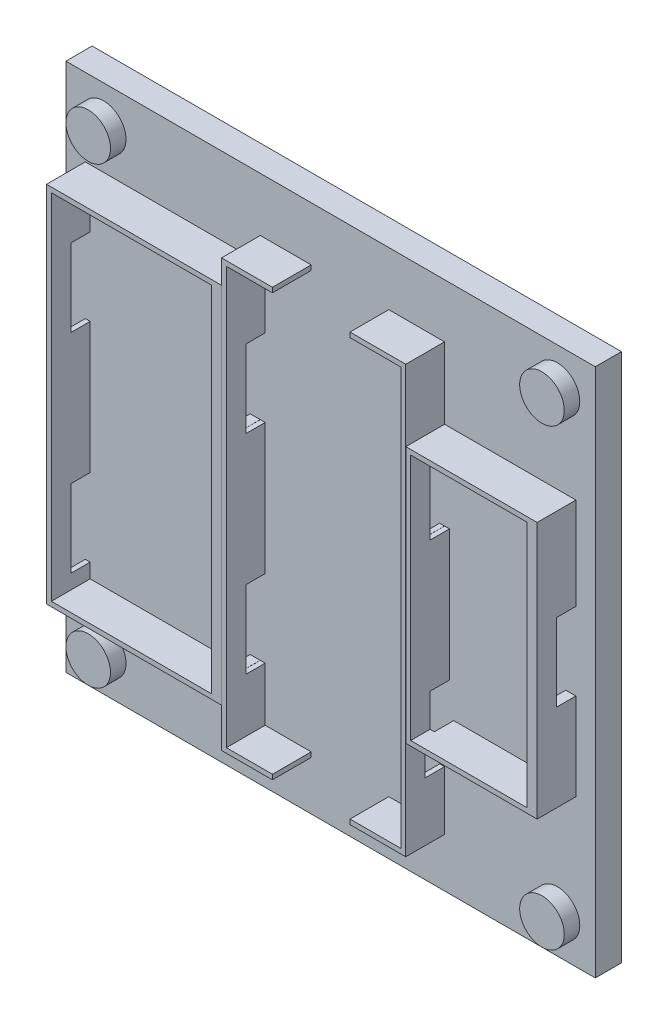
from build123d import *

# Parameters (mm, degrees)
SKICA1_W                 = 54.6
SKICA1_H                 = 54.6
SKICA1_R                 = 2.3
P_IDAT_VYSUNUT_M1_DEPTH  = 1.7
SKICA2_W                 = 54.6
SKICA2_H                 = 54.6
P_IDAT_VYSUNUT_M2_DEPTH  = 1
SKICA3_R                 = 2.3
P_IDAT_VYSUNUT_M3_DEPTH  = 1.6
SKICA4_W                 = 13.54
SKICA4_H                 = 26.5
SKICA4_W_2               = 19
SKICA4_H_2               = 44
SKICA4_W_3               = 18.04
SKICA4_H_3               = 37.5
P_IDAT_VYSUNUT_M4_DEPTH  = 4
SKICA5_W                 = 8
SKICA5_H                 = 4
ODEBRAT_VYSUNUT_M1_DEPTH = 6
SKICA6_W                 = 8
SKICA6_H                 = 4
ODEBRAT_VYSUNUT_M2_DEPTH = 6
SKICA7_W                 = 2
SKICA7_H                 = 8
ODEBRAT_VYSUNUT_M3_DEPTH = 38
SKICA8_W                 = 2
SKICA8_H                 = 8
ODEBRAT_VYSUNUT_M4_DEPTH = 13
SKICA11_W                = 16.5
SKICA11_H                = 36.5
SKICA11_W_2              = 18
SKICA11_H_2              = 43
SKICA11_W_3              = 12
SKICA11_H_3              = 25.5
ODEBRAT_VYSUNUT_M5_DEPTH = 4


with BuildPart() as part:
    # Skica1 → Přidat vysunutím1 (new body)
    with BuildSketch(Plane.XY):
        Rectangle(SKICA1_W, SKICA1_H)
        with Locations((-23.4, 23.4)):
            Circle(SKICA1_R, mode=Mode.SUBTRACT)
        with Locations((23.4, 23.4)):
            Circle(SKICA1_R, mode=Mode.SUBTRACT)
        with Locations((-23.4, -23.4)):
            Circle(SKICA1_R, mode=Mode.SUBTRACT)
        with Locations((23.4, -23.4)):
            Circle(SKICA1_R, mode=Mode.SUBTRACT)
    extrude(amount=P_IDAT_VYSUNUT_M1_DEPTH)

    # Skica2 → Přidat vysunutím2 (add)
    with BuildSketch(Plane.XY.offset(1.7)):
        Rectangle(SKICA2_W, SKICA2_H)
    extrude(amount=P_IDAT_VYSUNUT_M2_DEPTH)

    # Skica3 → Přidat vysunutím3 (add)
    with BuildSketch(Plane.XY.offset(2.7)):
        with Locations((-23.4, 23.4)):
            Circle(SKICA3_R)
        with Locations((23.4, 23.4)):
            Circle(SKICA3_R)
        with Locations((-23.4, -23.4)):
            Circle(SKICA3_R)
        with Locations((23.4, -23.4)):
            Circle(SKICA3_R)
    extrude(amount=P_IDAT_VYSUNUT_M3_DEPTH)

    # Skica4 → Přidat vysunutím4 (add)
    with BuildSketch(Plane.XY.offset(2.7)):
        with Locations((18.53, 1.14272147)):
            Rectangle(SKICA4_W, SKICA4_H)
        with Locations((2.25, -0.25)):
            Rectangle(SKICA4_W_2, SKICA4_H_2)
        with Locations((-16.28, 0.55)):
            Rectangle(SKICA4_W_3, SKICA4_H_3)
    extrude(amount=P_IDAT_VYSUNUT_M4_DEPTH)

    # Skica5 → Odebrat vysunutím1 (cut)
    with BuildSketch(Plane(origin=(0, -22.25, 0), x_dir=(-1, 0, 0), z_dir=(0, -1, 0))):
        with Locations((-2, -4.7)):
            Rectangle(SKICA5_W, SKICA5_H)
    extrude(amount=-ODEBRAT_VYSUNUT_M1_DEPTH, mode=Mode.SUBTRACT)

    # Skica6 → Odebrat vysunutím2 (cut)
    with BuildSketch(Plane(origin=(0, 21.75, 0), x_dir=(1, 0, 0), z_dir=(0, 1, 0))):
        with Locations((2, -4.7)):
            Rectangle(SKICA6_W, SKICA6_H)
    extrude(amount=-ODEBRAT_VYSUNUT_M2_DEPTH, mode=Mode.SUBTRACT)

    # Skica7 → Odebrat vysunutím3 (cut)
    with BuildSketch(Plane.ZY.offset(25.3)):
        with Locations((3.7, -12.2)):
            Rectangle(SKICA7_W, SKICA7_H)
        with Locations((3.7, 9.3)):
            Rectangle(SKICA7_W, SKICA7_H)
    extrude(amount=-ODEBRAT_VYSUNUT_M3_DEPTH, mode=Mode.SUBTRACT)

    # Skica8 → Odebrat vysunutím4 (cut)
    with BuildSketch(Plane(origin=(25.3, 0, 0), x_dir=(0, 0, -1), z_dir=(1, 0, 0))):
        with Locations((-3.7, 0.89272147)):
            Rectangle(SKICA8_W, SKICA8_H)
    extrude(amount=-ODEBRAT_VYSUNUT_M4_DEPTH, mode=Mode.SUBTRACT)

    # Skica11 → Odebrat vysunutím5 (cut)
    with BuildSketch(Plane.XY.offset(6.7)):
        with Locations((-16.55, 0.55)):
            Rectangle(SKICA11_W, SKICA11_H)
        with Locations((2.25, -0.25)):
            Rectangle(SKICA11_W_2, SKICA11_H_2)
        with Locations((18.26, 1.14272147)):
            Rectangle(SKICA11_W_3, SKICA11_H_3)
    extrude(amount=-ODEBRAT_VYSUNUT_M5_DEPTH, mode=Mode.SUBTRACT)


solid = part.part
